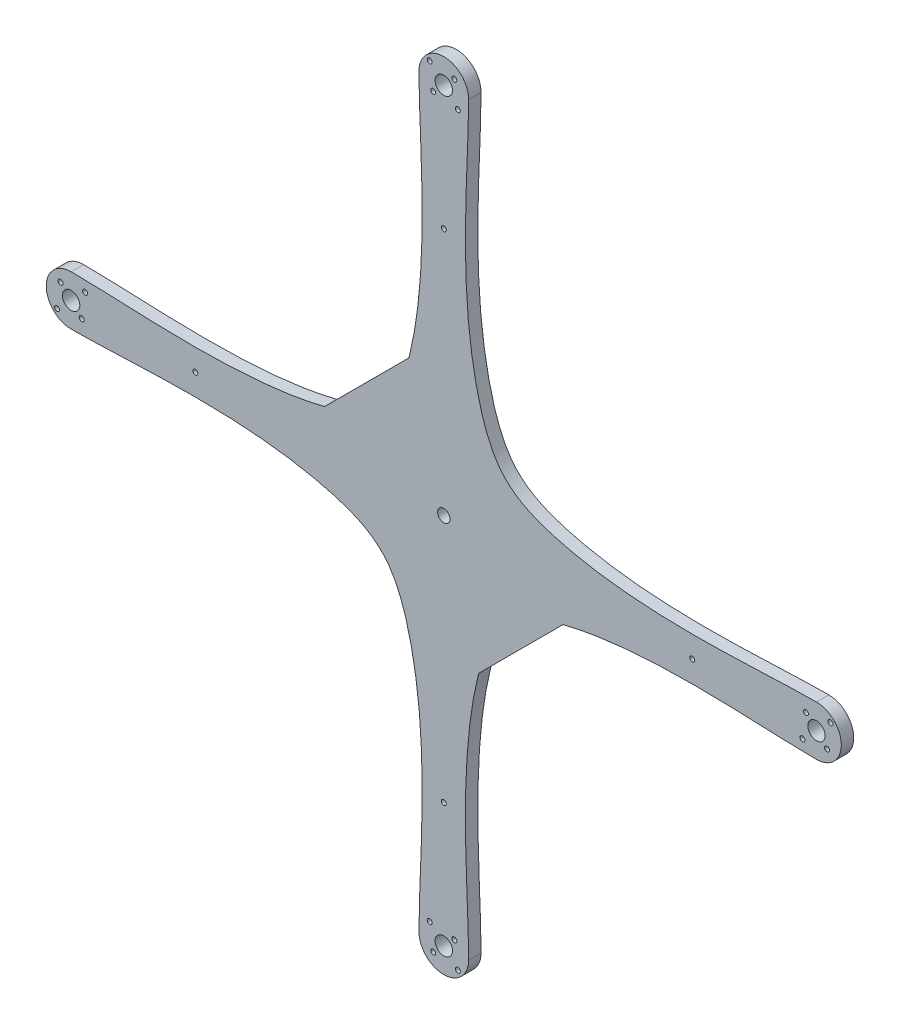
from build123d import *

# Parameters (mm, degrees)
SKETCH1_R           = 1
SKETCH1_R_2         = 3.5
SKETCH1_R_3         = 2.5
BOSS_EXTRUDE2_DEPTH = 5
SKETCH2_R           = 1
CUT_EXTRUDE1_DEPTH  = 6.0000001


with BuildPart() as part:
    # Sketch1 → Boss-Extrude2 (new body)
    with BuildSketch(Plane.XY):
        with BuildLine():
            Line((14, -48), (48, -14))
            add(Edge.make_bspline(
                [(150, -10), (125.11944581, -10), (83.330945639, -5.185645757), (48, -14)],
                knots=[0, 0, 0, 0, 0.361155478, 0.361155478, 0.361155478, 0.361155478], degree=3))
            ThreePointArc((150, -10), (160, 0), (150, 10))
            add(Edge.make_bspline(
                [(10, 150), (10, 125.11944581), (3.982288589, 72.885829079), (22.312428334, 22.313769088), (72.897562402, 3.980612308), (125.012148344, 10), (150, 10)],
                knots=[0, 0, 0, 0, 0.361155478, 0.451426989, 0.5416985, 0.902853978, 0.902853978, 0.902853978, 0.902853978], degree=3))
            ThreePointArc((10, 150), (0, 160), (-10, 150))
            add(Edge.make_bspline(
                [(-14, 48), (-5.184304681, 83.318876465), (-10, 125.012148344), (-10, 150)],
                knots=[0.5416985, 0.5416985, 0.5416985, 0.5416985, 0.902853978, 0.902853978, 0.902853978, 0.902853978], degree=3))
            Line((-14, 48), (-48, 14))
            add(Edge.make_bspline(
                [(-150, 10), (-125.11944581, 10), (-83.330945639, 5.185645757), (-48, 14)],
                knots=[0, 0, 0, 0, 0.361155478, 0.361155478, 0.361155478, 0.361155478], degree=3))
            ThreePointArc((-150, 10), (-160, 0), (-150, -10))
            add(Edge.make_bspline(
                [(-10, -150), (-10, -125.11944581), (-3.982288589, -72.885829079), (-22.312428334, -22.313769088), (-72.897562402, -3.980612308), (-125.012148344, -10), (-150, -10)],
                knots=[0, 0, 0, 0, 0.361155478, 0.451426989, 0.5416985, 0.902853978, 0.902853978, 0.902853978, 0.902853978], degree=3))
            ThreePointArc((-10, -150), (0, -160), (10, -150))
            add(Edge.make_bspline(
                [(14, -48), (5.184304681, -83.318876465), (10, -125.012148344), (10, -150)],
                knots=[0.5416985, 0.5416985, 0.5416985, 0.5416985, 0.902853978, 0.902853978, 0.902853978, 0.902853978], degree=3))
        make_face()
        with Locations((-155.656854249, -5.656854249)):
            Circle(SKETCH1_R, mode=Mode.SUBTRACT)
        with Locations((-144.343145751, 5.656854249)):
            Circle(SKETCH1_R, mode=Mode.SUBTRACT)
        with Locations((-145.757359313, -4.242640687)):
            Circle(SKETCH1_R, mode=Mode.SUBTRACT)
        with Locations((-154.242640687, 4.242640687)):
            Circle(SKETCH1_R, mode=Mode.SUBTRACT)
        with Locations((-5.656854249, 155.656854249)):
            Circle(SKETCH1_R, mode=Mode.SUBTRACT)
        with Locations((-4.242640687, 145.757359313)):
            Circle(SKETCH1_R, mode=Mode.SUBTRACT)
        with Locations((5.656854249, 144.343145751)):
            Circle(SKETCH1_R, mode=Mode.SUBTRACT)
        with Locations((4.242640687, 154.242640687)):
            Circle(SKETCH1_R, mode=Mode.SUBTRACT)
        with Locations((155.656854249, 5.65685425)):
            Circle(SKETCH1_R, mode=Mode.SUBTRACT)
        with Locations((145.757359313, 4.242640687)):
            Circle(SKETCH1_R, mode=Mode.SUBTRACT)
        with Locations((144.343145751, -5.656854249)):
            Circle(SKETCH1_R, mode=Mode.SUBTRACT)
        with Locations((154.242640687, -4.242640687)):
            Circle(SKETCH1_R, mode=Mode.SUBTRACT)
        with Locations((5.656854249, -155.656854249)):
            Circle(SKETCH1_R, mode=Mode.SUBTRACT)
        with Locations((4.242640687, -145.757359313)):
            Circle(SKETCH1_R, mode=Mode.SUBTRACT)
        with Locations((-5.656854249, -144.343145751)):
            Circle(SKETCH1_R, mode=Mode.SUBTRACT)
        with Locations((-4.242640687, -154.242640687)):
            Circle(SKETCH1_R, mode=Mode.SUBTRACT)
        with Locations((-150, 0)):
            Circle(SKETCH1_R_2, mode=Mode.SUBTRACT)
        with Locations((0, 150)):
            Circle(SKETCH1_R_2, mode=Mode.SUBTRACT)
        with Locations((150, 0)):
            Circle(SKETCH1_R_2, mode=Mode.SUBTRACT)
        with Locations((0, -150)):
            Circle(SKETCH1_R_2, mode=Mode.SUBTRACT)
        Circle(SKETCH1_R_3, mode=Mode.SUBTRACT)
    extrude(amount=BOSS_EXTRUDE2_DEPTH)

    # Sketch2 → Cut-Extrude1 (cut, through all)
    with BuildSketch(Plane.XY.offset(5)):
        with Locations((0, -100)):
            Circle(SKETCH2_R)
        with Locations((-100, 0)):
            Circle(SKETCH2_R)
        with Locations((0, 100)):
            Circle(SKETCH2_R)
        with Locations((100, 0)):
            Circle(SKETCH2_R)
    extrude(amount=-CUT_EXTRUDE1_DEPTH, mode=Mode.SUBTRACT)


solid = part.part
